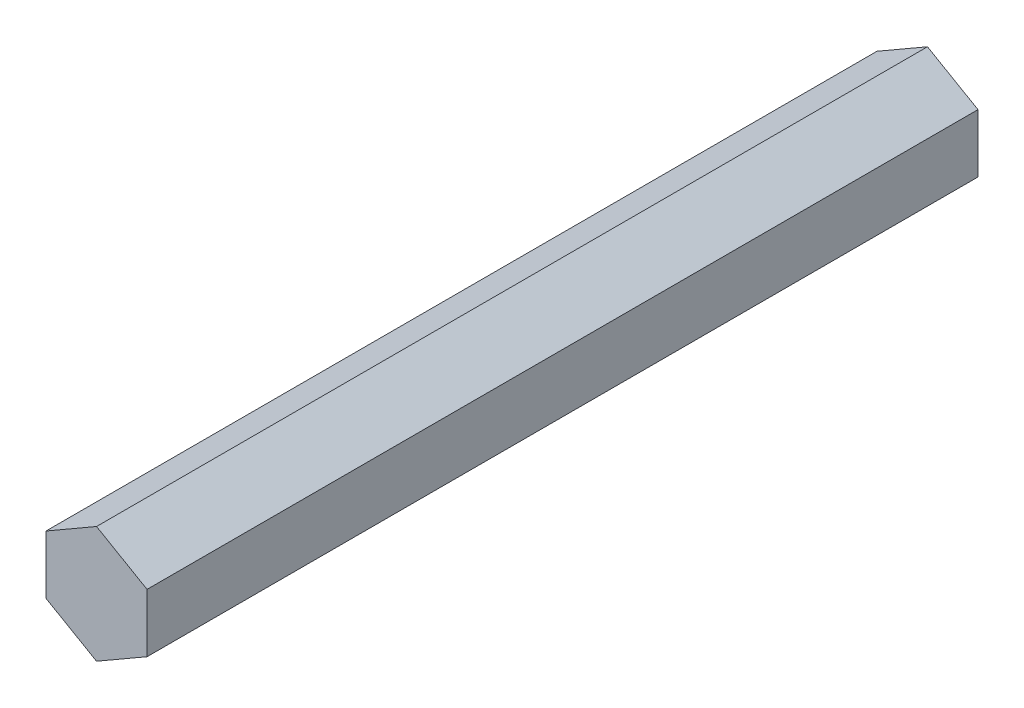
from build123d import *

# Parameters (mm, degrees)
SKETCH1_R           = 1.5
EXTRUDE1_DEPTH      = 18.5
EXTRUDE1_DEPTH_BACK = 18.5


with BuildPart() as part:
    # Sketch1 → Extrude1 (new, two sides)
    with BuildSketch(Plane.XY) as extrude1_sk:
        Polygon((2.25, -1.299038106), (2.25, 1.299038106), (0, 2.598076211), (-2.25, 1.299038106), (-2.25, -1.299038106), (0, -2.598076211), align=None)
        Circle(SKETCH1_R, mode=Mode.SUBTRACT)
        Circle(SKETCH1_R)
    extrude(amount=EXTRUDE1_DEPTH)
    extrude(extrude1_sk.sketch, amount=-EXTRUDE1_DEPTH_BACK)


solid = part.part
